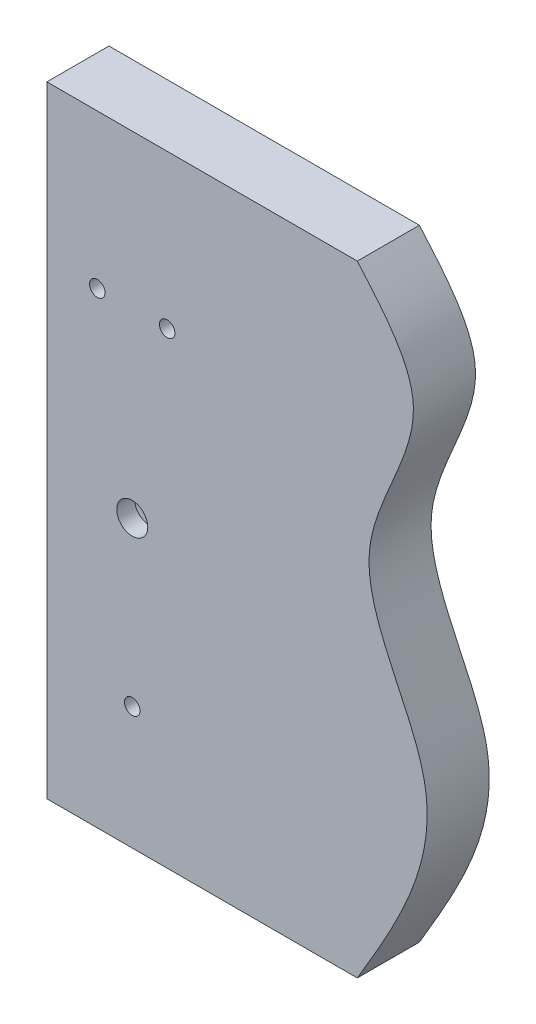
from build123d import *

# Parameters (mm, degrees)
EXTRUSION1_DEPTH        = 20
ESQUISSE2_W             = 22
ESQUISSE2_H             = 230
ENL_V_MAT_EXTRU_1_DEPTH = 3
ESQUISSE3_W             = 163
ESQUISSE3_H             = 77
ENL_V_MAT_EXTRU_2_DEPTH = 8.5
ESQUISSE4_R             = 10
ESQUISSE4_R_2           = 5
ENL_V_MAT_EXTRU_3_DEPTH = 41.0000001


with BuildPart() as part:
    # Esquisse1 → Extrusion1 (new body, symmetric)
    with BuildSketch(Plane.XY):
        with BuildLine():
            Line((-150, 200), (50, 200))
            add(Edge.make_bspline(
                [(50, 200), (66.879560662, 180.562572919), (108.794009551, 132.296562907), (27.278256401, 35.236557066), (123.473848535, -75.99379889), (75.892612143, -156.299492504), (50, -200)],
                knots=[0, 0, 0, 0, 0.163803914, 0.406749376, 0.677166684, 1, 1, 1, 1], degree=3))
            Line((50, -200), (-150, -200))
            Line((-150, -200), (-150, 200))
        make_face()
    extrude(amount=EXTRUSION1_DEPTH, both=True)

    # Esquisse2 → Enlèv. mat.-Extru.1 (cut)
    with BuildSketch(Plane.ZY.offset(150)):
        with Locations((0, -35)):
            Rectangle(ESQUISSE2_W, ESQUISSE2_H)
    extrude(amount=-ENL_V_MAT_EXTRU_1_DEPTH, mode=Mode.SUBTRACT)

    # Esquisse3 → Enlèv. mat.-Extru.2 (cut, symmetric)
    with BuildSketch(Plane(origin=(37.152504758, -36.321343777, 0), x_dir=(0, 1, 0), z_dir=(0, 0, 1))):
        with Locations((1.321343777, 145.652504758)):
            Rectangle(ESQUISSE3_W, ESQUISSE3_H)
    extrude(amount=ENL_V_MAT_EXTRU_2_DEPTH, both=True, mode=Mode.SUBTRACT)

    # Esquisse4 → Enlèv. mat.-Extru.3 (cut, through all)
    with BuildSketch(Plane.XY.offset(20)):
        with Locations((-95, -16)):
            Circle(ESQUISSE4_R)
        with Locations((-117.5, 101)):
            Circle(ESQUISSE4_R_2)
        with Locations((-95, -121)):
            Circle(ESQUISSE4_R_2)
        with Locations((-72.5, 101)):
            Circle(ESQUISSE4_R_2)
    extrude(amount=-ENL_V_MAT_EXTRU_3_DEPTH, mode=Mode.SUBTRACT)


solid = part.part
